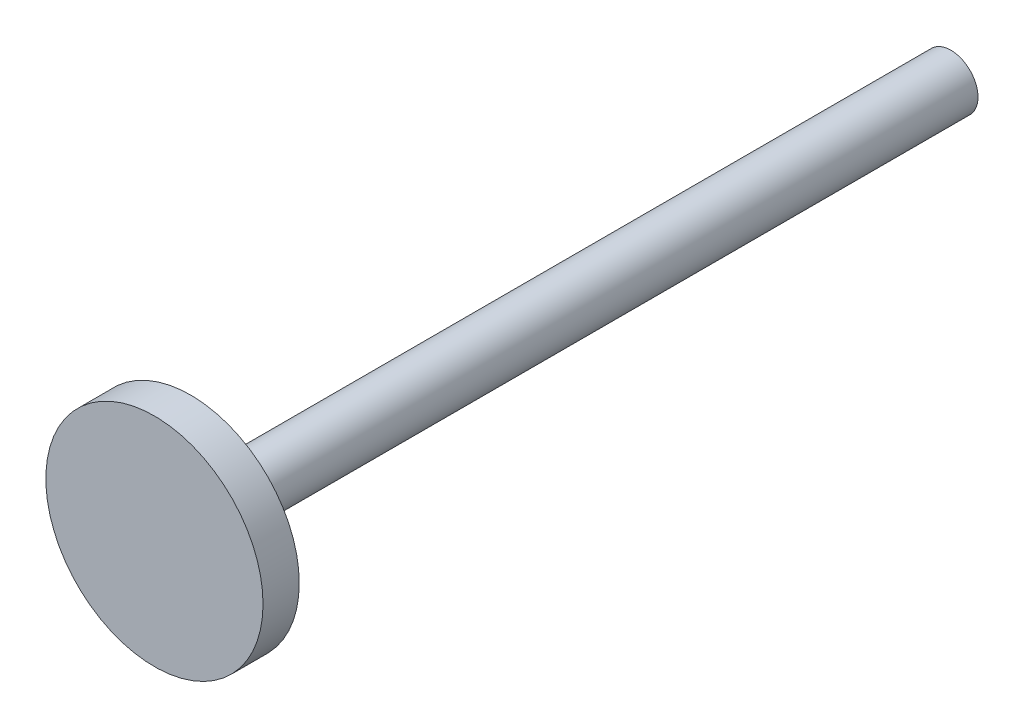
from build123d import *

# Parameters (mm, degrees)
SKETCH1_R           = 9.525
BOSS_EXTRUDE1_DEPTH = 279.4
SKETCH2_R           = 38.1
BOSS_EXTRUDE2_DEPTH = 12.7


with BuildPart() as part:
    # Sketch1 → Boss-Extrude1 (new body)
    with BuildSketch(Plane.XY):
        Circle(SKETCH1_R)
    extrude(amount=BOSS_EXTRUDE1_DEPTH)

    # Sketch2 → Boss-Extrude2 (add)
    with BuildSketch(Plane.XY.offset(279.4)):
        Circle(SKETCH2_R)
    extrude(amount=-BOSS_EXTRUDE2_DEPTH)


solid = part.part
